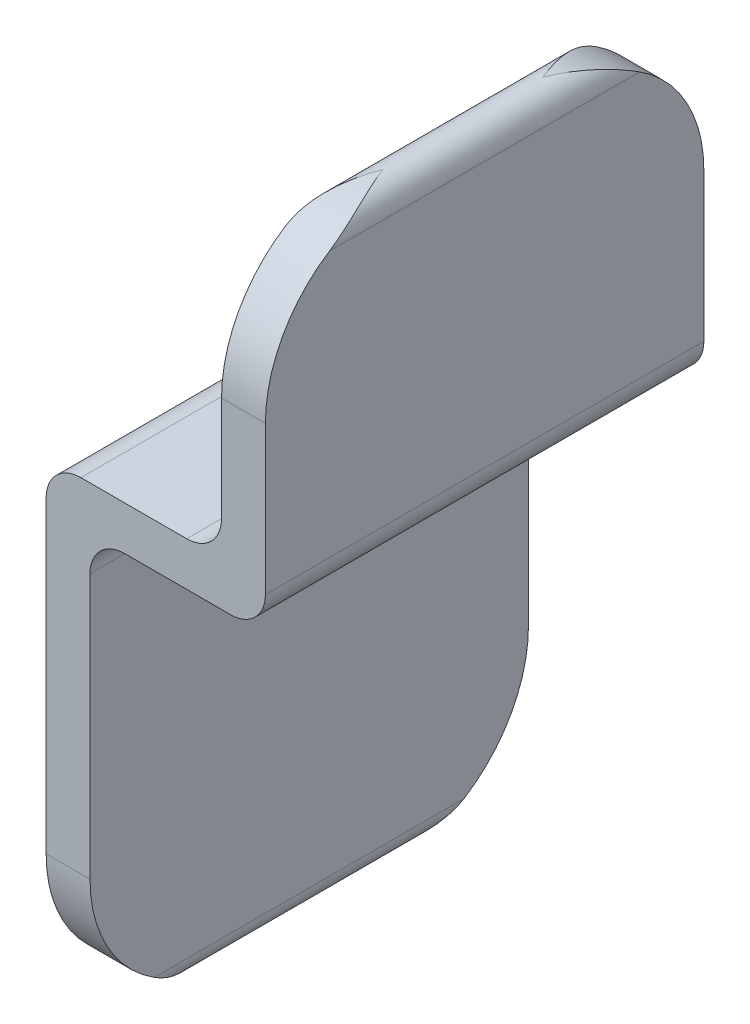
from build123d import *

# Parameters (mm, degrees)
BOSS_EXTRUDE1_DEPTH = 20
CUT_EXTRUDE1_DEPTH  = 55


with BuildPart() as part:
    # Sketch1 → Boss-Extrude1 (new body)
    with BuildSketch(Plane.XY):
        with BuildLine():
            Line((-1, 0), (-1, -10.1125))
            ThreePointArc((-1, -10.1125), (-1.464967985, -11.235032015), (-2.5875, -11.7))
            Line((-2.5875, -11.7), (-7.4125, -11.7))
            ThreePointArc((-7.4125, -11.7), (-8.535032015, -12.164967985), (-9, -13.2875))
            Line((-9, -13.2875), (-9, -32.7))
            ThreePointArc((-9, -32.7), (-8, -33.7), (-7, -32.7))
            Line((-7, -32.7), (-7, -15.2875))
            ThreePointArc((-7, -15.2875), (-6.535032015, -14.164967985), (-5.4125, -13.7))
            Line((-5.4125, -13.7), (-0.5875, -13.7))
            ThreePointArc((-0.5875, -13.7), (0.535032015, -13.235032015), (1, -12.1125))
            Line((1, -12.1125), (1, 0))
            ThreePointArc((1, 0), (0, 1), (-1, 0))
        make_face()
    extrude(amount=BOSS_EXTRUDE1_DEPTH)

    # Sketch2 → Cut-Extrude1 (cut)
    with BuildSketch(Plane.ZY.offset(9)):
        with BuildLine():
            ThreePointArc((0, -5.35), (1.859871939, -0.859871939), (6.35, 1))
            Line((6.35, 1), (0, 1))
            Line((0, 1), (0, -5.35))
        make_face()
        with BuildLine():
            Line((20, 1), (13.65, 1))
            ThreePointArc((13.65, 1), (18.140128061, -0.859871939), (20, -5.35))
            Line((20, -5.35), (20, 1))
        make_face()
        with BuildLine():
            Line((20, -32.7), (20, -27.35))
            ThreePointArc((20, -27.35), (19.219687686, -30.399767053), (17.070526275, -32.7))
            Line((17.070526275, -32.7), (20, -32.7))
        make_face()
        with BuildLine():
            Line((20, -33.7), (20, -32.7))
            Line((20, -32.7), (17.070526275, -32.7))
            ThreePointArc((17.070526275, -32.7), (15.431852968, -33.444874896), (13.65, -33.7))
            Line((13.65, -33.7), (20, -33.7))
        make_face()
        with BuildLine():
            ThreePointArc((2.929473725, -32.7), (0.780312314, -30.399767053), (0, -27.35))
            Line((0, -27.35), (0, -32.7))
            Line((0, -32.7), (2.929473725, -32.7))
        make_face()
        with BuildLine():
            Line((2.929473725, -32.7), (0, -32.7))
            Line((0, -32.7), (0, -33.7))
            Line((0, -33.7), (6.35, -33.7))
            ThreePointArc((6.35, -33.7), (4.568147032, -33.444874896), (2.929473725, -32.7))
        make_face()
    extrude(amount=-CUT_EXTRUDE1_DEPTH, mode=Mode.SUBTRACT)


solid = part.part
